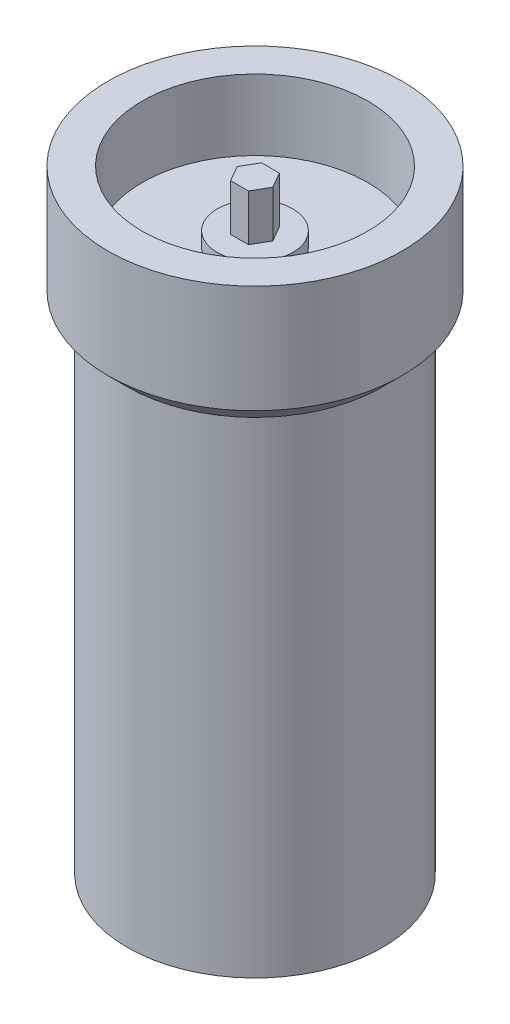
from build123d import *

# Parameters (mm, degrees)
SKETCH2_R           = 23
CUT_EXTRUDE1_DEPTH  = 14.4
BOSS_EXTRUDE1_DEPTH = 12.5
SKETCH4_R           = 7.7
BOSS_EXTRUDE2_DEPTH = 3


with BuildPart() as part:
    # Sketch1 → Revolve1 (revolve)
    with BuildSketch(Plane.XY):
        Polygon((0, 0), (0, 125), (30, 125), (30, 103), (26, 99), (26, 0), align=None)
    revolve(axis=Axis((0, 0, 0), (0, 1, 0)))

    # Sketch2 → Cut-Extrude1 (cut)
    with BuildSketch(Plane(origin=(0, 125, 0), x_dir=(1, 0, 0), z_dir=(0, 1, 0))):
        Circle(SKETCH2_R)
    extrude(amount=-CUT_EXTRUDE1_DEPTH, mode=Mode.SUBTRACT)


with BuildPart() as body_2:
    # Sketch3 → Boss-Extrude1 (new body)
    with BuildSketch(Plane(origin=(0, 110.6, 0), x_dir=(1, 0, 0), z_dir=(0, 1, 0))):
        Polygon((3.637306696, 0), (1.818653348, 3.15), (-1.818653348, 3.15), (-3.637306696, 0), (-1.818653348, -3.15), (1.818653348, -3.15), align=None)
    extrude(amount=BOSS_EXTRUDE1_DEPTH)


with BuildPart() as body_3:
    # Sketch4 → Boss-Extrude2 (new body)
    with BuildSketch(Plane(origin=(0, 110.6, 0), x_dir=(1, 0, 0), z_dir=(0, 1, 0))):
        Circle(SKETCH4_R)
    extrude(amount=BOSS_EXTRUDE2_DEPTH)


solid = Compound([part.part, body_2.part, body_3.part])
